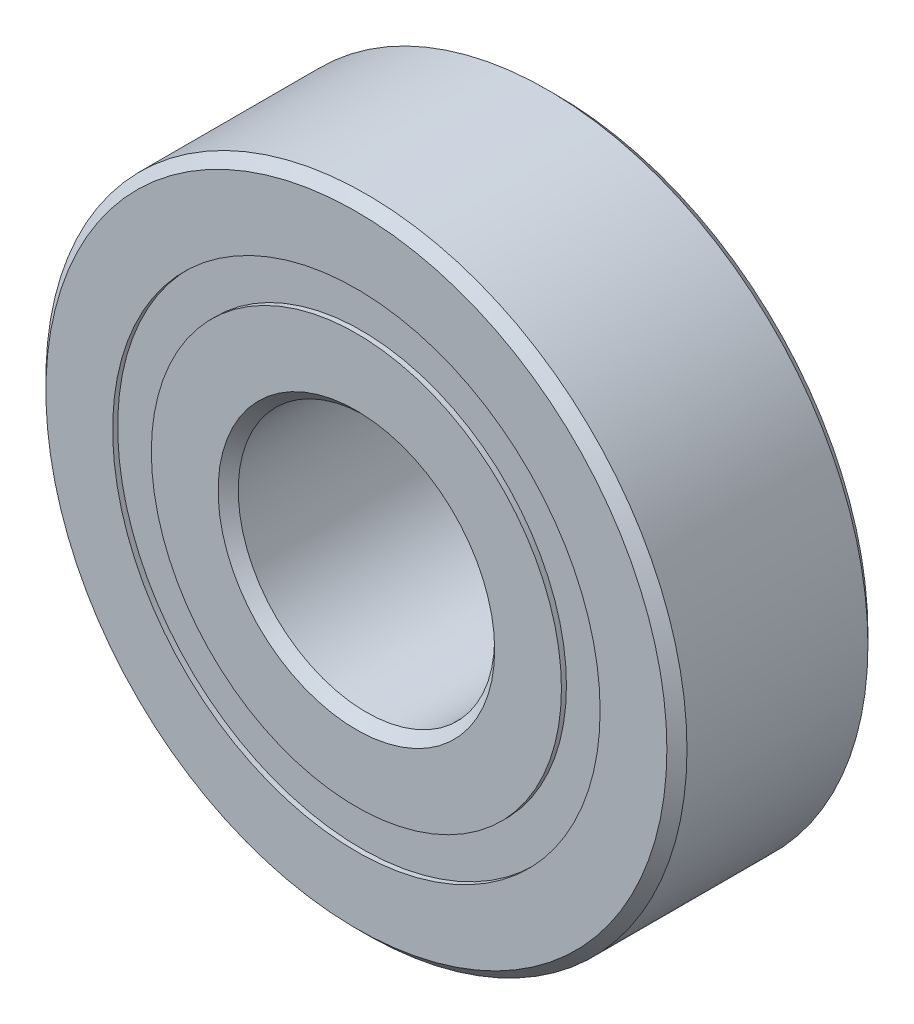
from build123d import *

# Parameters (mm, degrees)
CIRPATTERN1_COUNT = 10
SKETCH5_W         = 1.15919535
SKETCH5_H         = 0.957942858


with BuildPart() as part:
    # Sketch1 → Revolve1 (revolve)
    with BuildSketch(Plane(origin=(0, 0, 0), x_dir=(0, 0, -1), z_dir=(1, 0, 0))):
        with BuildLine():
            Line((2.24028, 7.9375), (-2.24028, 7.9375))
            Line((-2.24028, 7.9375), (-2.4892, 7.68858))
            Line((-2.4892, 7.68858), (-2.4892, 6.035221429))
            Line((-2.4892, 6.035221429), (-1.106311111, 6.035221429))
            ThreePointArc((-1.106311111, 6.035221429), (0, 6.76179465), (1.106311111, 6.035221429))
            Line((1.106311111, 6.035221429), (2.4892, 6.035221429))
            Line((2.4892, 6.035221429), (2.4892, 7.68858))
            Line((2.4892, 7.68858), (2.24028, 7.9375))
        make_face()
    revolve(axis=Axis((0, 0, 2.4892), (0, 0, -1)))


with BuildPart() as body_2:
    # Sketch3 → Revolve3 (revolve)
    with BuildSketch(Plane(origin=(0, 0, 0), x_dir=(0, 0, -1), z_dir=(1, 0, 0))):
        with BuildLine():
            Line((-2.4892, 5.077278571), (-1.106311111, 5.077278571))
            ThreePointArc((-1.106311111, 5.077278571), (0, 4.35070535), (1.106311111, 5.077278571))
            Line((1.106311111, 5.077278571), (2.4892, 5.077278571))
            Line((2.4892, 5.077278571), (2.4892, 3.42392))
            Line((2.4892, 3.42392), (2.24028, 3.175))
            Line((2.24028, 3.175), (-2.24028, 3.175))
            Line((-2.24028, 3.175), (-2.4892, 3.42392))
            Line((-2.4892, 3.42392), (-2.4892, 5.077278571))
        make_face()
    revolve(axis=Axis((0, 0, 2.4892), (0, 0, -1)))


with BuildPart() as body_3:
    # Sketch4 → Revolve4 (revolve)
    with BuildSketch(Plane(origin=(0, 0, 0), x_dir=(0, 0, -1), z_dir=(1, 0, 0))):
        with BuildLine():
            Line((-1.20554465, 5.55625), (1.20554465, 5.55625))
            ThreePointArc((1.20554465, 5.55625), (0, 6.76179465), (-1.20554465, 5.55625))
        make_face()
    revolve(axis=Axis((0, 5.55625, 1.20554465), (0, 0, -1)))


with BuildPart() as cirpattern1_1:
    # CirPattern1: pattern copy
    add(body_3.part.rotate(Axis((0, 0, 0), (0, 0, 1)), 1 * 360 / CIRPATTERN1_COUNT))


with BuildPart() as cirpattern1_2:
    # CirPattern1: pattern copy
    add(body_3.part.rotate(Axis((0, 0, 0), (0, 0, 1)), 2 * 360 / CIRPATTERN1_COUNT))


with BuildPart() as cirpattern1_3:
    # CirPattern1: pattern copy
    add(body_3.part.rotate(Axis((0, 0, 0), (0, 0, 1)), 3 * 360 / CIRPATTERN1_COUNT))


with BuildPart() as cirpattern1_4:
    # CirPattern1: pattern copy
    add(body_3.part.rotate(Axis((0, 0, 0), (0, 0, 1)), 4 * 360 / CIRPATTERN1_COUNT))


with BuildPart() as cirpattern1_5:
    # CirPattern1: pattern copy
    add(body_3.part.rotate(Axis((0, 0, 0), (0, 0, 1)), 5 * 360 / CIRPATTERN1_COUNT))


with BuildPart() as cirpattern1_6:
    # CirPattern1: pattern copy
    add(body_3.part.rotate(Axis((0, 0, 0), (0, 0, 1)), 6 * 360 / CIRPATTERN1_COUNT))


with BuildPart() as cirpattern1_7:
    # CirPattern1: pattern copy
    add(body_3.part.rotate(Axis((0, 0, 0), (0, 0, 1)), 7 * 360 / CIRPATTERN1_COUNT))


with BuildPart() as cirpattern1_8:
    # CirPattern1: pattern copy
    add(body_3.part.rotate(Axis((0, 0, 0), (0, 0, 1)), 8 * 360 / CIRPATTERN1_COUNT))


with BuildPart() as cirpattern1_9:
    # CirPattern1: pattern copy
    add(body_3.part.rotate(Axis((0, 0, 0), (0, 0, 1)), 9 * 360 / CIRPATTERN1_COUNT))


with BuildPart() as body_13:
    # Sketch5 → Revolve5 (revolve)
    with BuildSketch(Plane(origin=(0, 0, 0), x_dir=(0, 0, -1), z_dir=(1, 0, 0))):
        with Locations((-1.785142325, 5.55625)):
            Rectangle(SKETCH5_W, SKETCH5_H)
        with Locations((1.785142325, 5.55625)):
            Rectangle(SKETCH5_W, SKETCH5_H)
    revolve(axis=Axis((0, 0, 2.4892), (0, 0, -1)))


solid = Compound([part.part, body_2.part, body_3.part, cirpattern1_1.part, cirpattern1_2.part, cirpattern1_3.part, cirpattern1_4.part, cirpattern1_5.part, cirpattern1_6.part, cirpattern1_7.part, cirpattern1_8.part, cirpattern1_9.part, body_13.part])
